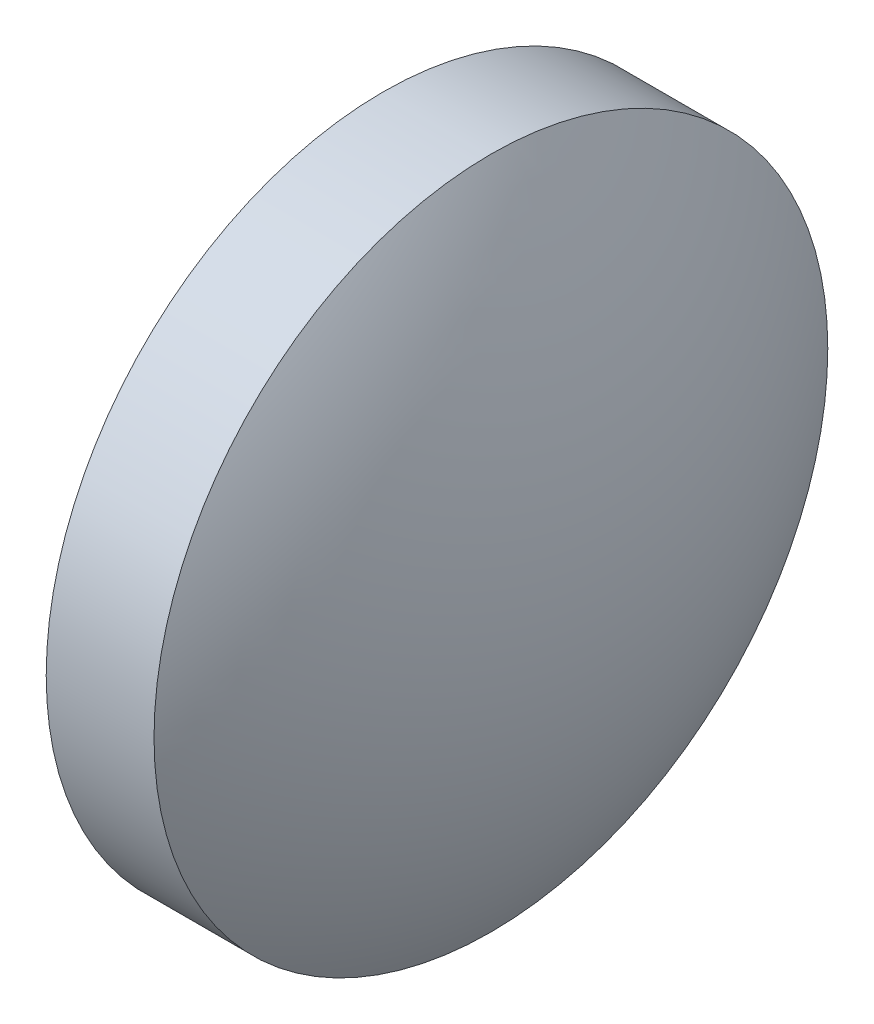
from build123d import *

# Parameters (mm, degrees)
SKETCH_1_ONE_SIDE_W = 2
SKETCH_1_ONE_SIDE_H = 6.25


with BuildPart() as part:
    # 草图1 one side → 旋转1 (revolve)
    with BuildSketch(Plane.XY):
        with Locations((42.548323708, 27.050252472)):
            Rectangle(SKETCH_1_ONE_SIDE_W, SKETCH_1_ONE_SIDE_H)
        with BuildLine():
            Line((39.773361953, 23.925252472), (41.548323708, 23.925252472))
            Line((41.548323708, 23.925252472), (41.548323708, 30.175252472))
            ThreePointArc((41.548323708, 30.175252472), (40.225706001, 27.173828669), (39.773361953, 23.925252472))
        make_face()
        with BuildLine():
            Line((43.548323708, 23.925252472), (45.323323708, 23.925252472))
            ThreePointArc((45.323323708, 23.925252472), (44.870969557, 27.173833893), (43.548323708, 30.175252472))
            Line((43.548323708, 30.175252472), (43.548323708, 23.925252472))
        make_face()
    revolve(axis=Axis((36.019747028, 23.925252472, 0), (1, 0, 0)))


solid = part.part
